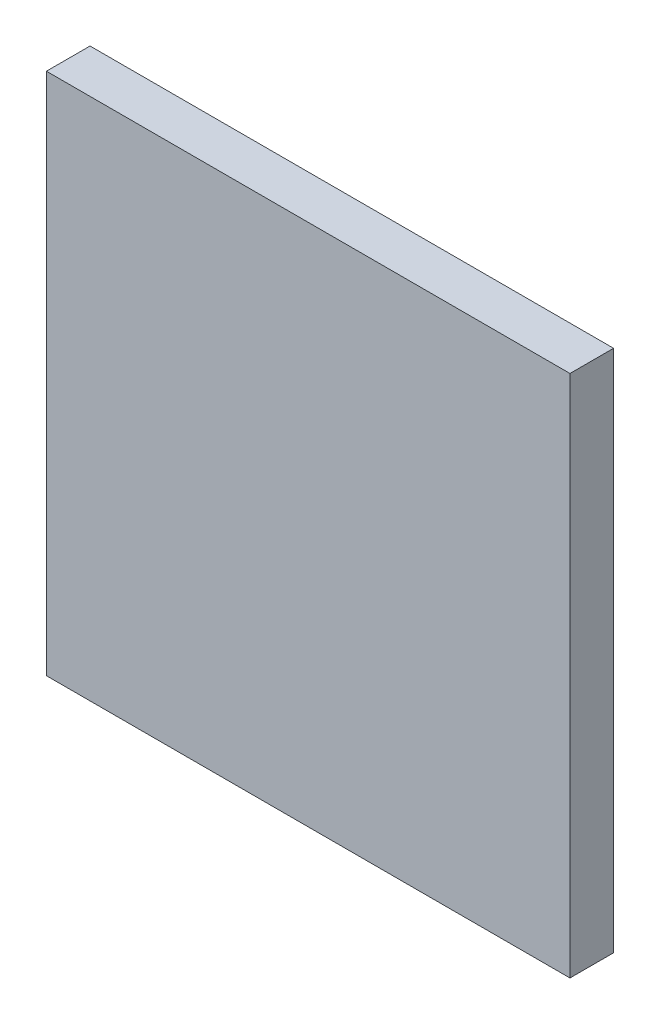
from build123d import *

# Parameters (mm, degrees)
SKETCH1_W           = 6.35
SKETCH1_H           = 76.2
BOSS_EXTRUDE1_DEPTH = 76.2


with BuildPart() as part:
    # Sketch1 → Boss-Extrude1 (new body)
    with BuildSketch(Plane(origin=(0, 0, 0), x_dir=(0, 0, -1), z_dir=(1, 0, 0))):
        Rectangle(SKETCH1_W, SKETCH1_H)
    extrude(amount=BOSS_EXTRUDE1_DEPTH)


solid = part.part
